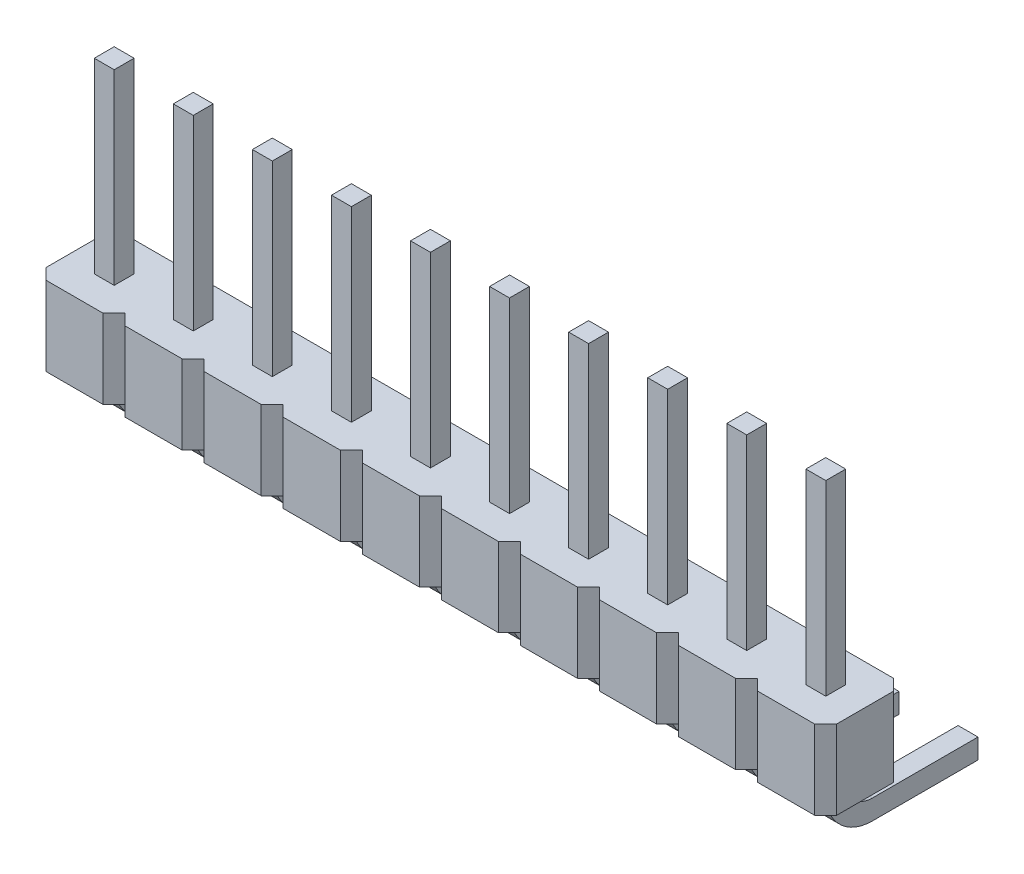
from build123d import *

# Parameters (mm, degrees)
SKETCH1_W                  = 0.636
SKETCH1_H                  = 0.636
BOSS_EXTRUDE1_DEPTH        = 2.54
BOSS_EXTRU_1_DEPTH         = 0.64
R_P_TITION_LIN_AIRE1_COUNT = 10
R_P_TITION_LIN_AIRE1_PITCH = 2.54


with BuildPart() as part:
    # Sketch1 → Boss-Extrude1 (new body)
    with BuildSketch(Plane.XZ):
        Polygon((-0.353553391, -2.186446609), (-2.186446609, -2.186446609), (-2.54, -1.832893219), (-2.54, 0), (-2.186446609, 0.353553391), (-0.353553391, 0.353553391), (0, 0), (0, -1.832893219), align=None)
        with Locations((-1.27, -0.916446609)):
            Rectangle(SKETCH1_W, SKETCH1_H, mode=Mode.SUBTRACT)
    boss_extrude1 = extrude(amount=-BOSS_EXTRUDE1_DEPTH)

    # Esquisse1 → Boss.-Extru.1 (add)
    with BuildSketch(Plane(origin=(-1.588, 0, 0), x_dir=(0, 0, -1), z_dir=(1, 0, 0))):
        with BuildLine():
            Line((0.598446609, 8.54), (0.598446609, -0.18))
            ThreePointArc((0.598446609, -0.18), (1.037786438, -1.240660172), (2.098446609, -1.68))
            Line((2.098446609, -1.68), (5.488446609, -1.68))
            Line((5.488446609, -1.68), (5.488446609, -1.04))
            Line((5.488446609, -1.04), (2.098446609, -1.04))
            ThreePointArc((2.098446609, -1.04), (1.490334778, -0.788111832), (1.238446609, -0.18))
            Line((1.238446609, -0.18), (1.238446609, 8.54))
            Line((1.238446609, 8.54), (0.598446609, 8.54))
        make_face()
    boss_extru_1 = extrude(amount=BOSS_EXTRU_1_DEPTH)

    # Répétition linéaire1: Boss-Extrude1, Boss.-Extru.1 ×10
    with Locations(*[(i * R_P_TITION_LIN_AIRE1_PITCH, 0, 0) for i in range(1, R_P_TITION_LIN_AIRE1_COUNT)]):
        add(boss_extrude1)
        add(boss_extru_1)


solid = part.part
